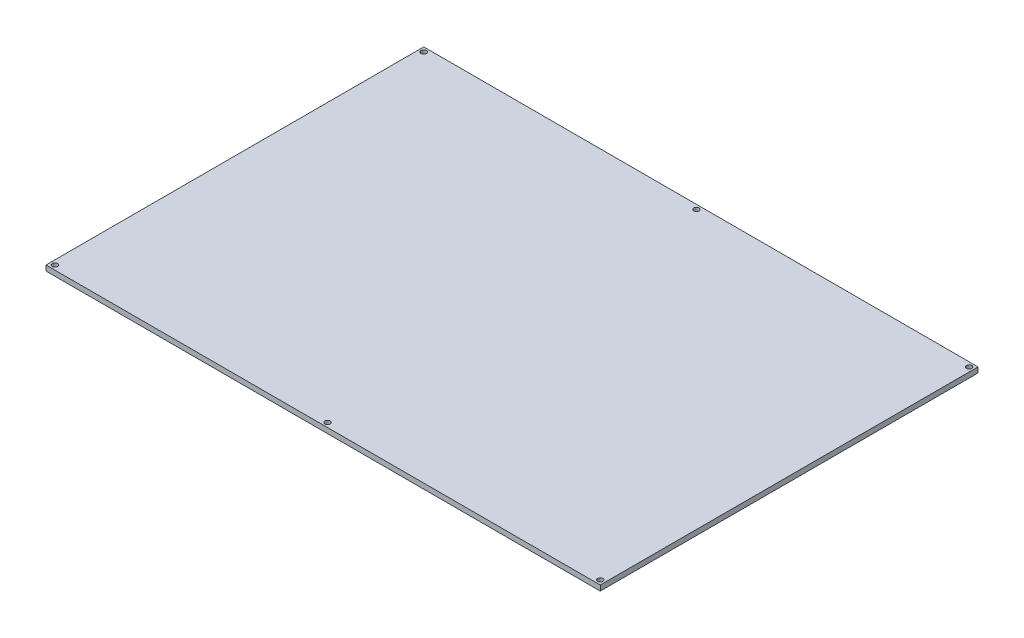
from build123d import *

# Parameters (mm, degrees)
SKETCH1_W           = 314
SKETCH1_H           = 214
SKETCH1_R           = 1.5
BOSS_EXTRUDE1_DEPTH = 3
SKETCH2_R           = 1.5
CUT_EXTRUDE1_DEPTH  = 10


with BuildPart() as part:
    # Sketch1 → Boss-Extrude1 (new body)
    with BuildSketch(Plane(origin=(0, 0, 0), x_dir=(1, 0, 0), z_dir=(0, 1, 0))):
        with Locations((-157, 107)):
            Rectangle(SKETCH1_W, SKETCH1_H)
        with Locations((-311.5, 211.5)):
            Circle(SKETCH1_R, mode=Mode.SUBTRACT)
        with Locations((-311.5, 2.5)):
            Circle(SKETCH1_R, mode=Mode.SUBTRACT)
        with Locations((-2.5, 2.5)):
            Circle(SKETCH1_R, mode=Mode.SUBTRACT)
        with Locations((-2.5, 211.5)):
            Circle(SKETCH1_R, mode=Mode.SUBTRACT)
    extrude(amount=BOSS_EXTRUDE1_DEPTH)

    # Sketch2 → Cut-Extrude1 (cut)
    with BuildSketch(Plane.XZ):
        with Locations((-157, -2.5)):
            Circle(SKETCH2_R)
        with Locations((-157, -211.5)):
            Circle(SKETCH2_R)
    extrude(amount=-CUT_EXTRUDE1_DEPTH, mode=Mode.SUBTRACT)


solid = part.part
